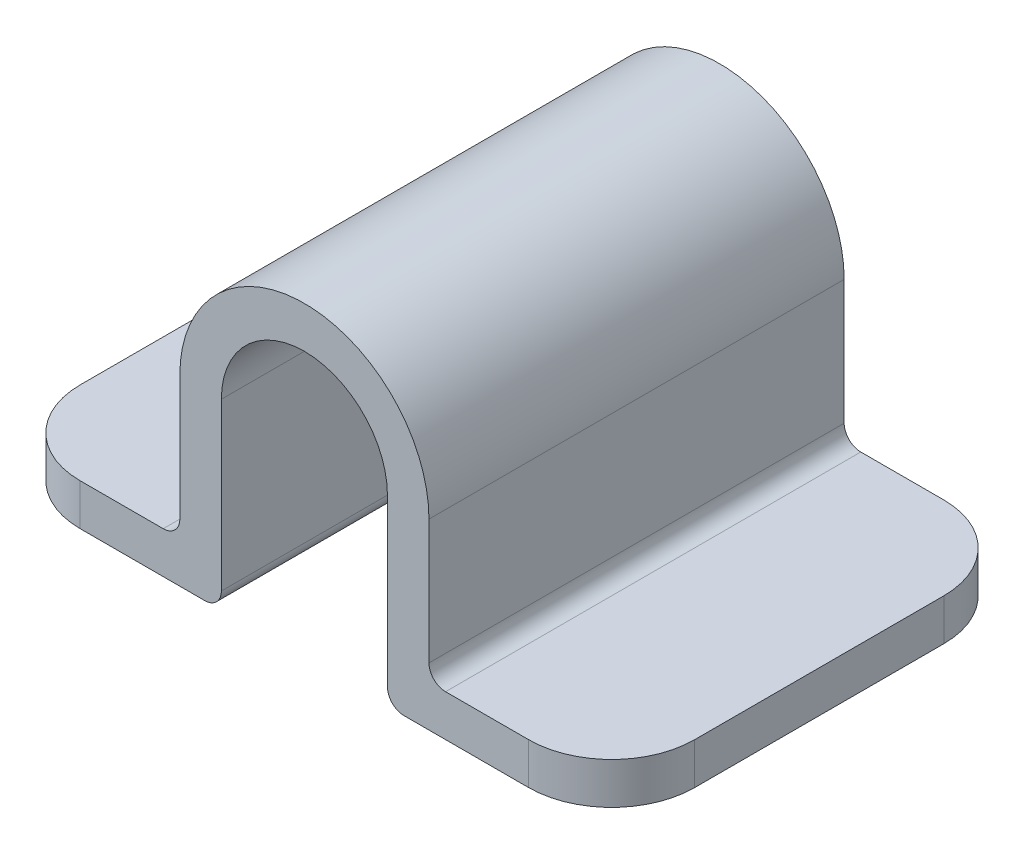
from build123d import *

# Parameters (mm, degrees)
BOSS_EXTRUDE4_DEPTH = 50
FILLET1_R           = 10


with BuildPart() as part:
    # Sketch6 → Boss-Extrude4 (new body)
    with BuildSketch(Plane.XY):
        with BuildLine():
            Line((10, 0), (10, -20))
            ThreePointArc((10, -20), (10.585786438, -21.414213562), (12, -22))
            Line((12, -22), (37, -22))
            Line((37, -22), (37, -17))
            Line((37, -17), (17, -17))
            ThreePointArc((17, -17), (15.585786438, -16.414213562), (15, -15))
            Line((15, -15), (15, 0))
            ThreePointArc((15, 0), (0, 15), (-15, 0))
            Line((-15, 0), (-15, -15))
            ThreePointArc((-15, -15), (-15.585786438, -16.414213562), (-17, -17))
            Line((-17, -17), (-37, -17))
            Line((-37, -17), (-37, -22))
            Line((-37, -22), (-12, -22))
            ThreePointArc((-12, -22), (-10.585786438, -21.414213562), (-10, -20))
            Line((-10, -20), (-10, 0))
            ThreePointArc((-10, 0), (0, 10), (10, 0))
        make_face()
    extrude(amount=-BOSS_EXTRUDE4_DEPTH)

    # Fillet1
    fillet1_edges = [part.edges().sort_by_distance(p)[0] for p in [
        (37, -19.5, 0),
        (-37, -19.5, 0),
        (-37, -19.5, -50),
        (37, -19.5, -50),
    ]]
    fillet(fillet1_edges, radius=FILLET1_R)


solid = part.part
